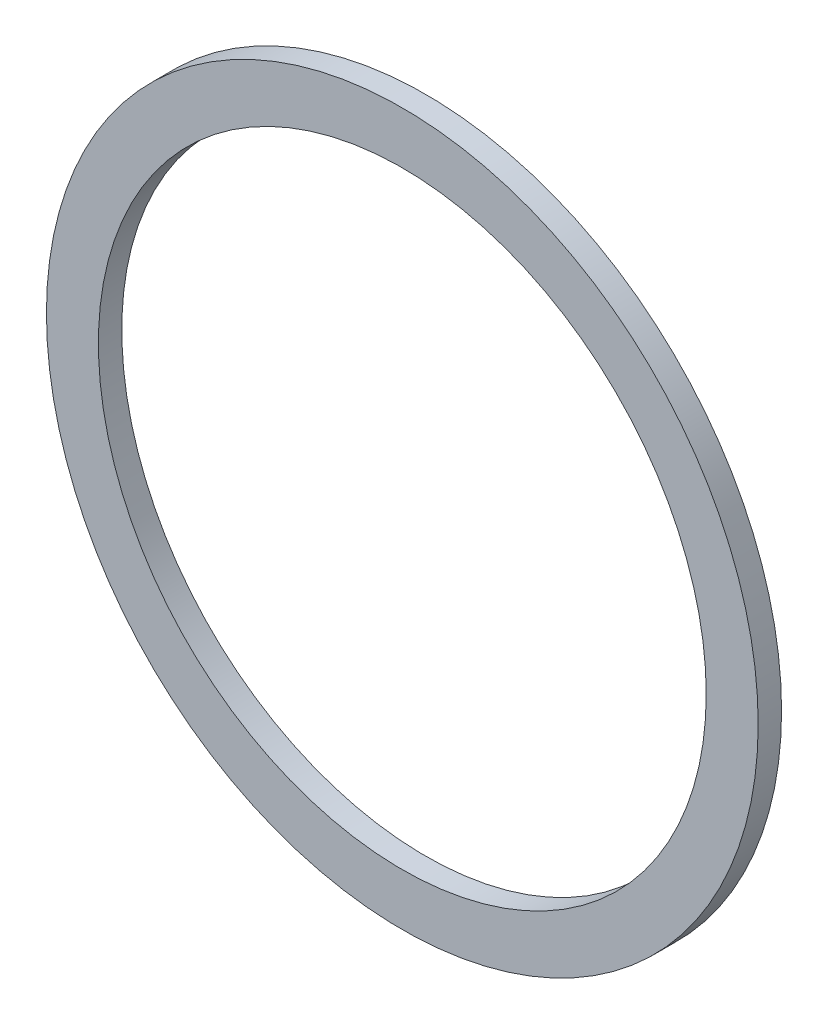
from build123d import *

# Parameters (mm, degrees)
SKETCH1_R           = 27.4
SKETCH1_R_2         = 23.4
BOSS_EXTRUDE1_DEPTH = 1.8


with BuildPart() as part:
    # Sketch1 → Boss-Extrude1 (new body)
    with BuildSketch(Plane.XY):
        Circle(SKETCH1_R)
        Circle(SKETCH1_R_2, mode=Mode.SUBTRACT)
    extrude(amount=BOSS_EXTRUDE1_DEPTH)


solid = part.part
